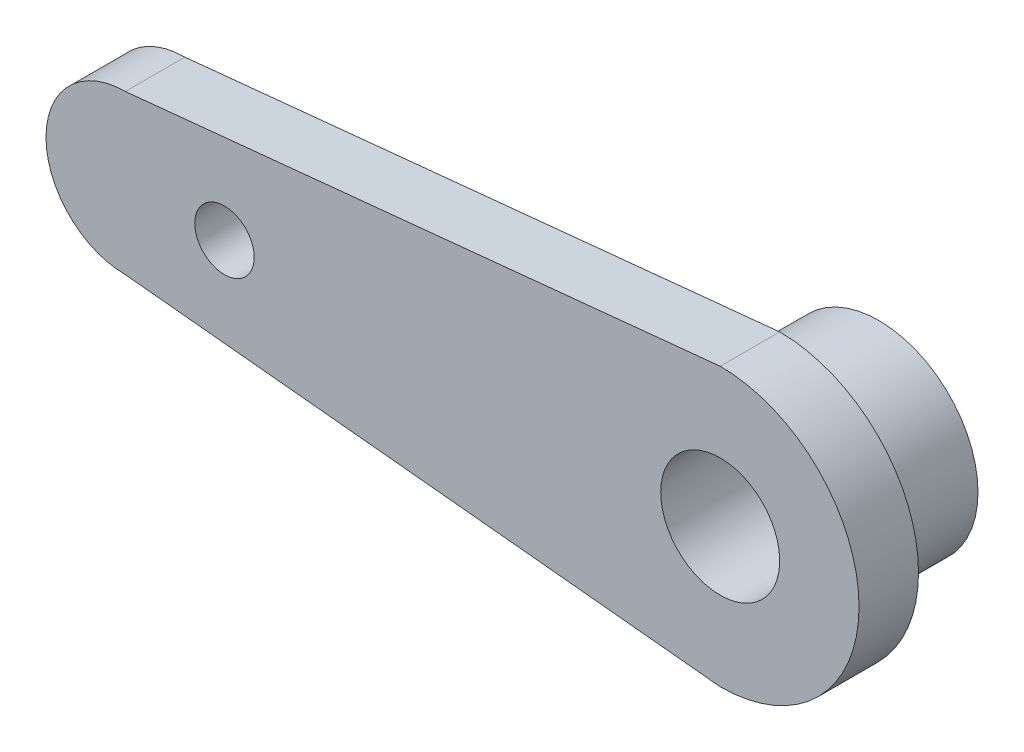
from build123d import *

# Parameters (mm, degrees)
SKETCH1_R           = 5
SKETCH1_R_2         = 3
BOSS_EXTRUDE1_DEPTH = 5
BOSS_EXTRUDE2_DEPTH = 3
SKETCH3_R           = 1.5
CUT_EXTRUDE1_DEPTH  = 3
SKETCH4_R           = 3
CUT_EXTRUDE2_DEPTH  = 3


with BuildPart() as part:
    # Sketch1 → Boss-Extrude1 (new body)
    with BuildSketch(Plane.XY):
        Circle(SKETCH1_R)
        Circle(SKETCH1_R_2, mode=Mode.SUBTRACT)
    extrude(amount=BOSS_EXTRUDE1_DEPTH)

    # Sketch2 → Boss-Extrude2 (add)
    with BuildSketch(Plane.XY.offset(5)):
        with BuildLine():
            Line((-30, 4), (0, 7))
            ThreePointArc((0, 7), (7, 0), (0, -7))
            Line((0, -7), (-30, -4))
            ThreePointArc((-30, -4), (-34, 0), (-30, 4))
        make_face()
    extrude(amount=BOSS_EXTRUDE2_DEPTH)

    # Sketch3 → Cut-Extrude1 (cut)
    with BuildSketch(Plane(origin=(0, 0, 5), x_dir=(-1, 0, 0), z_dir=(0, 0, -1))):
        with Locations((25, 0)):
            Circle(SKETCH3_R)
    extrude(amount=-CUT_EXTRUDE1_DEPTH, mode=Mode.SUBTRACT)

    # Sketch4 → Cut-Extrude2 (cut)
    with BuildSketch(Plane(origin=(0, 0, 5), x_dir=(-1, 0, 0), z_dir=(0, 0, -1))):
        Circle(SKETCH4_R)
    extrude(amount=-CUT_EXTRUDE2_DEPTH, mode=Mode.SUBTRACT)


solid = part.part
